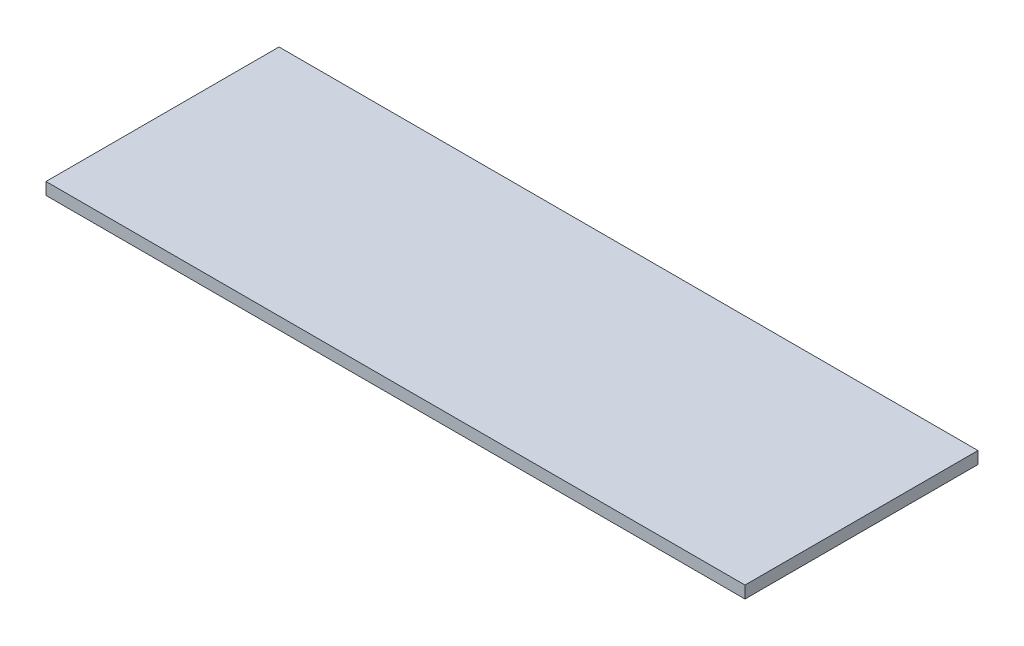
from build123d import *

# Parameters (mm, degrees)
SKETCH1_W           = 1828.8
SKETCH1_H           = 609.6
BOSS_EXTRUDE1_DEPTH = 31.75


with BuildPart() as part:
    # Sketch1 → Boss-Extrude1 (new body)
    with BuildSketch(Plane(origin=(0, 0, 0), x_dir=(1, 0, 0), z_dir=(0, 1, 0))):
        Rectangle(SKETCH1_W, SKETCH1_H)
    extrude(amount=BOSS_EXTRUDE1_DEPTH)


solid = part.part
